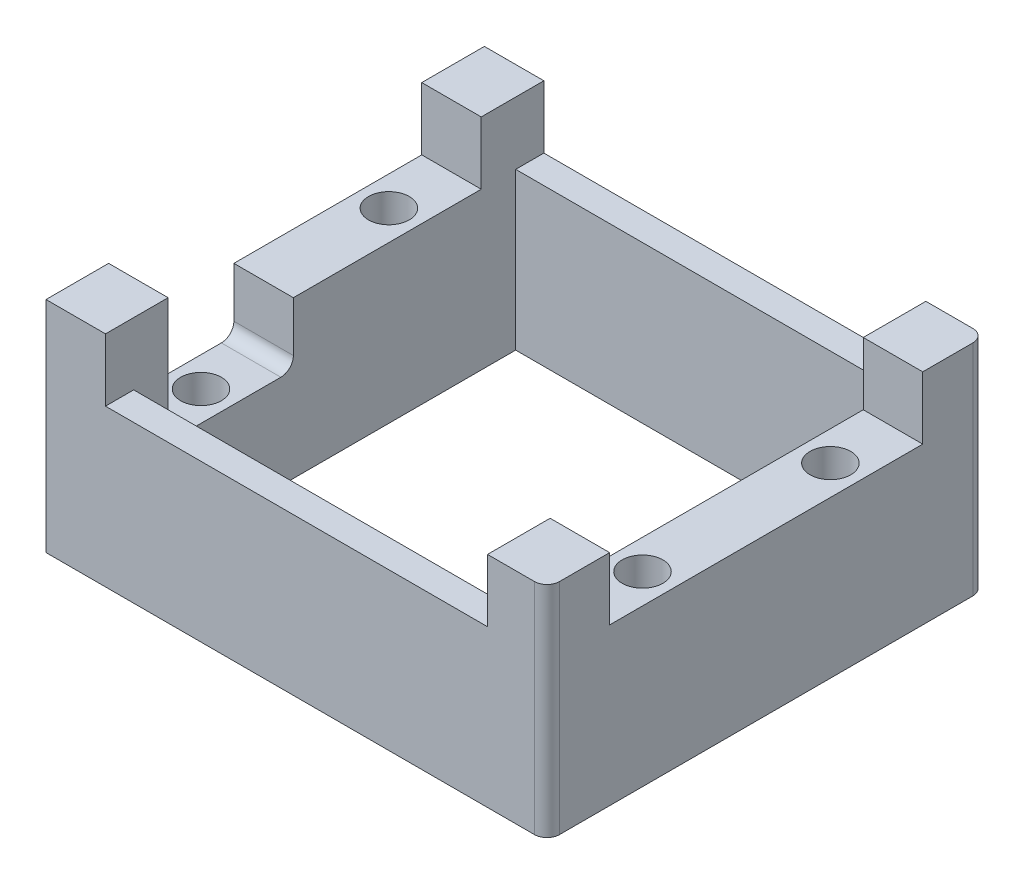
from build123d import *

# Parameters (mm, degrees)
SKETCH1_W                       = 80
SKETCH1_H                       = 70
BOSS_EXTRUDE1_DEPTH             = 25
SKETCH2_W                       = 61
SKETCH2_H                       = 61
CUT_EXTRUDE1_DEPTH              = 26
SKETCH3_W                       = 9.5
SKETCH3_H                       = 10
BOSS_EXTRUDE2_DEPTH             = 10
FILLET1_R                       = 2
FILLET4_R                       = 2
CBORE_FOR_M3_SHCS1_D            = 3.4
CBORE_FOR_M3_SHCS1_CBORE_D      = 6.5
CBORE_FOR_M3_SHCS1_CBORE_DEPTH  = 22
TAP_DRILL_FOR_M3X0_5_TAP1_D     = 2.5
TAP_DRILL_FOR_M3X0_5_TAP1_DEPTH = 8
TAP_DRILL_FOR_M3X0_5_TAP1_TIP   = 0.751075774
CUT_EXTRUDE2_REACH              = 82
SKETCH9_W                       = 20
SKETCH9_H                       = 10
FILLET5_R                       = 2


with BuildPart() as part:
    # Sketch1 → Boss-Extrude1 (new body)
    with BuildSketch(Plane(origin=(0, 0, 0), x_dir=(1, 0, 0), z_dir=(0, 1, 0))):
        with Locations((4.767506632, 4.187819453)):
            Rectangle(SKETCH1_W, SKETCH1_H)
    extrude(amount=BOSS_EXTRUDE1_DEPTH)

    # Sketch2 → Cut-Extrude1 (cut, through all)
    with BuildSketch(Plane(origin=(0, 25, 0), x_dir=(1, 0, 0), z_dir=(0, 1, 0))):
        with Locations((4.767506632, 4.187819453)):
            Rectangle(SKETCH2_W, SKETCH2_H)
    extrude(amount=-CUT_EXTRUDE1_DEPTH, mode=Mode.SUBTRACT)

    # Sketch3 → Boss-Extrude2 (add)
    with BuildSketch(Plane(origin=(0, 25, 0), x_dir=(1, 0, 0), z_dir=(0, 1, 0))):
        with Locations((-30.482493368, 34.187819453)):
            Rectangle(SKETCH3_W, SKETCH3_H)
        with Locations((40.017506632, 34.187819453)):
            Rectangle(SKETCH3_W, SKETCH3_H)
        with Locations((-30.482493368, -25.812180547)):
            Rectangle(SKETCH3_W, SKETCH3_H)
        with Locations((40.017506632, -25.812180547)):
            Rectangle(SKETCH3_W, SKETCH3_H)
    extrude(amount=BOSS_EXTRUDE2_DEPTH)

    # Fillet1
    fillet1_edges = [part.edges().sort_by_distance(p)[0] for p in [
        (44.767506632, 17.5, 30.812180547),
    ]]
    fillet(fillet1_edges, radius=FILLET1_R)

    # Fillet4
    fillet4_edges = [part.edges().sort_by_distance(p)[0] for p in [
        (44.767506632, 17.5, -39.187819453),
    ]]
    fillet(fillet4_edges, radius=FILLET4_R)

    # CBORE for M3 SHCS1 (through all)
    with Locations(Plane(origin=(-30.482493368, 25, -19.187819453), x_dir=(0, 0, 1), z_dir=(0, 1, 0))):
        with Locations((0, 0), (30, 0), (30, 70.5), (0, 70.5)):
            CounterBoreHole(CBORE_FOR_M3_SHCS1_D / 2, CBORE_FOR_M3_SHCS1_CBORE_D / 2, CBORE_FOR_M3_SHCS1_CBORE_DEPTH)

    # Tap Drill for M3x0.5 Tap1
    with Locations(Plane(origin=(-35.232493368, 20, 25.812180547), x_dir=(0, 0, -1), z_dir=(-1, 0, 0))):
        with Locations((0, 0), (60, 0)):
            Hole(TAP_DRILL_FOR_M3X0_5_TAP1_D / 2, depth=TAP_DRILL_FOR_M3X0_5_TAP1_DEPTH)
            with Locations((0, 0, -(TAP_DRILL_FOR_M3X0_5_TAP1_DEPTH + TAP_DRILL_FOR_M3X0_5_TAP1_TIP / 2))):  # 118° drill point
                Cone(0, TAP_DRILL_FOR_M3X0_5_TAP1_D / 2, TAP_DRILL_FOR_M3X0_5_TAP1_TIP, mode=Mode.SUBTRACT)

    # Sketch9 → Cut-Extrude2 (cut, up to next)
    with BuildSketch(Plane.ZY.offset(35.232493368), mode=Mode.PRIVATE) as cut_extrude2_sk1:
        with Locations((10.812180547, 20)):
            Rectangle(SKETCH9_W, SKETCH9_H)
    cut_extrude2_tool1 = extrude(cut_extrude2_sk1.sketch, amount=-CUT_EXTRUDE2_REACH, mode=Mode.PRIVATE) & part.part
    add(cut_extrude2_tool1.solids().sort_by_distance((-35.232493, 20, 10.812181))[0], mode=Mode.SUBTRACT)

    # Fillet5
    fillet5_edges = [part.edges().sort_by_distance(p)[0] for p in [
        (-30.482493368, 15, 0.812180547),
        (-30.482493368, 15, 20.812180547),
    ]]
    fillet(fillet5_edges, radius=FILLET5_R)


solid = part.part
